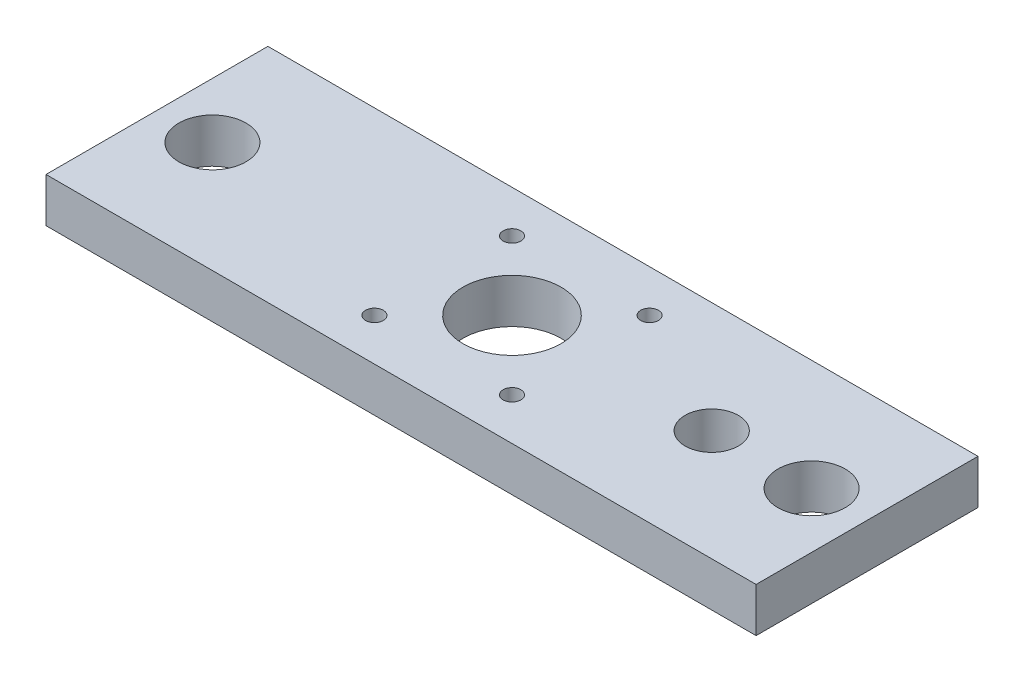
from build123d import *

# Parameters (mm, degrees)
SKETCH1_W           = 160
SKETCH1_H           = 50
SKETCH1_R           = 11.05
SKETCH1_R_2         = 2
SKETCH1_R_3         = 7.575
SKETCH1_R_4         = 6
BOSS_EXTRUDE1_DEPTH = 10


with BuildPart() as part:
    # Sketch1 → Boss-Extrude1 (new body)
    with BuildSketch(Plane(origin=(0, 0, 0), x_dir=(1, 0, 0), z_dir=(0, 1, 0))):
        Rectangle(SKETCH1_W, SKETCH1_H)
        Circle(SKETCH1_R, mode=Mode.SUBTRACT)
        with Locations((15.5, 15.5)):
            Circle(SKETCH1_R_2, mode=Mode.SUBTRACT)
        with Locations((-15.5, 15.5)):
            Circle(SKETCH1_R_2, mode=Mode.SUBTRACT)
        with Locations((-15.5, -15.5)):
            Circle(SKETCH1_R_2, mode=Mode.SUBTRACT)
        with Locations((15.5, -15.5)):
            Circle(SKETCH1_R_2, mode=Mode.SUBTRACT)
        with Locations((-67.5, 0)):
            Circle(SKETCH1_R_3, mode=Mode.SUBTRACT)
        with Locations((67.5, 0)):
            Circle(SKETCH1_R_3, mode=Mode.SUBTRACT)
        with Locations((45, 0)):
            Circle(SKETCH1_R_4, mode=Mode.SUBTRACT)
    extrude(amount=BOSS_EXTRUDE1_DEPTH)


solid = part.part
